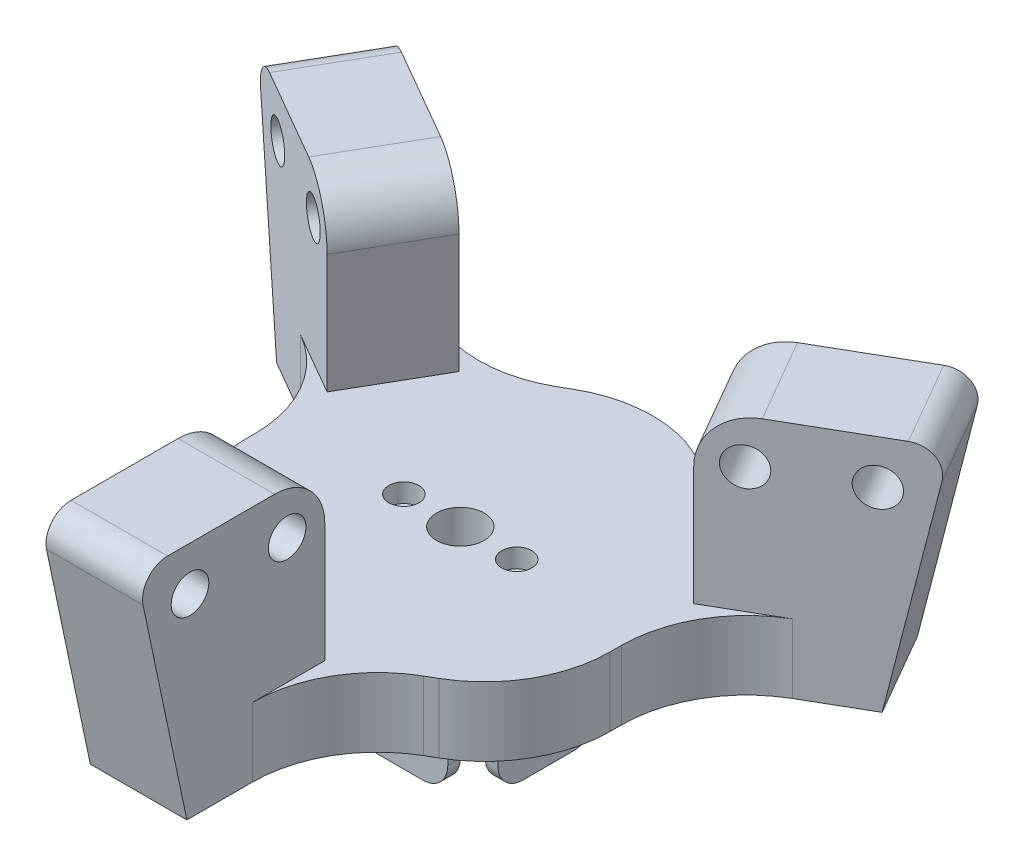
from build123d import *

# Parameters (mm, degrees)
BOSS_EXTRUSION_DEPTH     = 5.5
SCHIZZO2_W               = 7.7
SCHIZZO2_H               = 15
EXTERNAL_EXTRUSION_DEPTH = 13.5
SCHIZZO3_R               = 1.9
CETRAL_HOLE_DEPTH        = 6.5
SKETCH1_R                = 1.5
CUT_EXTRUDE1_DEPTH       = 7.7
CIRPATTERN1_COUNT        = 3
FILLET1_R                = 10
FILLET2_R                = 4
FILLET3_R                = 2
SKETCH2_R                = 0.5
CUT_EXTRUDE2_DEPTH       = 7.7
SKETCH2_5_W              = 1
SKETCH2_5_H              = 8
SKETCH2_5_W_2            = 10
SKETCH2_5_H_2            = 1
BOSS_EXTRUDE1_DEPTH      = 7.5
FILLET4_R                = 2
CHAMFER1_SIZE            = 2
SKETCH2_6_R              = 1.2
SKETCH2_6_R_2            = 1.9
SKETCH2_6_R_3            = 0.5
CUT_EXTRUDE4_DEPTH       = 1.5
CUT_EXTRUDE5_START       = -5.5
SKETCH2_7_R              = 1.2
SKETCH2_7_R_2            = 0.5
CUT_EXTRUDE5_DEPTH       = 1.5
SKETCH4_R                = 2.5
CUT_EXTRUDE6_DEPTH       = 0.7


with BuildPart() as part:
    # Schizzo1 → Boss extrusion (new body)
    with BuildSketch(Plane(origin=(0, 0, 0), x_dir=(1, 0, 0), z_dir=(0, 1, 0))):
        Polygon((-27.611313476, 11.495802195), (-14.620932419, 3.995802195), (-14.620932419, -8.441399268), (-3.85, -14.66), (-3.85, -29.66), (3.85, -29.66), (3.85, -14.66), (14.620932419, -8.441399268), (14.620932419, 3.995802195), (27.611313476, 11.495802195), (23.761313476, 18.164197805), (10.770932419, 10.664197805), (0, 16.882798536), (-10.770932419, 10.664197805), (-23.761313476, 18.164197805), align=None)
    extrude(amount=BOSS_EXTRUSION_DEPTH)

    # Schizzo2 → external extrusion (add)
    with BuildSketch(Plane(origin=(0, 5.5, 0), x_dir=(1, 0, 0), z_dir=(0, 1, 0))):
        Polygon((-23.761313476, 18.164197805), (-27.611313476, 11.495802195), (-14.620932419, 3.995802195), (-10.770932419, 10.664197805), align=None)
        with Locations((0, -22.16)):
            Rectangle(SCHIZZO2_W, SCHIZZO2_H)
        Polygon((10.770932419, 10.664197805), (14.620932419, 3.995802195), (27.611313476, 11.495802195), (23.761313476, 18.164197805), align=None)
    extrude(amount=EXTERNAL_EXTRUSION_DEPTH)

    # Schizzo3 → cetral hole (cut, through all)
    with BuildSketch(Plane(origin=(0, 5.5, 0), x_dir=(1, 0, 0), z_dir=(0, 1, 0))):
        Circle(SCHIZZO3_R)
    extrude(amount=-CETRAL_HOLE_DEPTH, mode=Mode.SUBTRACT)

    # Sketch1 → Cut-Extrude1 (cut)
    with BuildSketch(Plane.ZY.offset(3.85)):
        with Locations((17.66, 15.5)):
            Circle(SKETCH1_R)
        with Locations((25.41, 15.5)):
            Circle(SKETCH1_R)
        Polygon((29.66, 19), (29.66, 0), (25.66, 0), align=None)
    cut_extrude1 = extrude(amount=-CUT_EXTRUDE1_DEPTH, mode=Mode.SUBTRACT)

    # CirPattern1: Cut-Extrude1 ×3 about axis
    cirpattern1_axis = Axis((0, 0, 0), (0, 1, 0))
    for i in range(1, CIRPATTERN1_COUNT):
        add(cut_extrude1.rotate(cirpattern1_axis, i * 360 / CIRPATTERN1_COUNT), mode=Mode.SUBTRACT)

    # Fillet1
    fillet1_edges = [part.edges().sort_by_distance(p)[0] for p in [
        (-3.85, 2.75, 14.66),
        (-14.620932419, 2.75, 8.441399268),
        (-14.620932419, 2.75, -3.995802195),
        (-10.770932419, 2.75, -10.664197805),
        (0, 2.75, -16.882798536),
        (10.770932419, 2.75, -10.664197805),
        (14.620932419, 2.75, -3.995802195),
        (14.620932419, 2.75, 8.441399268),
        (3.85, 2.75, 14.66),
    ]]
    fillet(fillet1_edges, radius=FILLET1_R)

    # Fillet2
    fillet2_edges = [part.edges().sort_by_distance(p)[0] for p in [
        (-12.695932419, 19, -7.33),
        (0, 19, 14.66),
        (12.695932419, 19, -7.33),
    ]]
    fillet(fillet2_edges, radius=FILLET2_R)

    # Fillet3
    fillet3_edges = [part.edges().sort_by_distance(p)[0] for p in [
        (-25.686313476, 19, -14.83),
        (0, 19, 29.66),
        (25.686313476, 19, -14.83),
    ]]
    fillet(fillet3_edges, radius=FILLET3_R)

    # Sketch2 → Cut-Extrude2 (cut)
    with BuildSketch(Plane.XZ):
        with Locations((-4.5, 0)):
            Circle(SKETCH2_R)
        with Locations((4.5, 0)):
            Circle(SKETCH2_R)
    extrude(amount=-CUT_EXTRUDE2_DEPTH, mode=Mode.SUBTRACT)

    # Sketch2_5 → Boss-Extrude1 (add)
    with BuildSketch(Plane.XZ):
        with Locations((6.5, 0)):
            Rectangle(SKETCH2_5_W, SKETCH2_5_H)
        with Locations((0, 5.5)):
            Rectangle(SKETCH2_5_W_2, SKETCH2_5_H_2)
        with Locations((-6.5, 0)):
            Rectangle(SKETCH2_5_W, SKETCH2_5_H)
        with Locations((0, -5.5)):
            Rectangle(SKETCH2_5_W_2, SKETCH2_5_H_2)
    extrude(amount=BOSS_EXTRUDE1_DEPTH)

    # Fillet4
    fillet4_edges = [part.edges().sort_by_distance(p)[0] for p in [
        (6.5, -7.5, 4),
        (6.5, -7.5, -4),
        (-5, -7.5, 5.5),
        (5, -7.5, 5.5),
        (-6.5, -7.5, -4),
        (-6.5, -7.5, 4),
        (5, -7.5, -5.5),
        (-5, -7.5, -5.5),
    ]]
    fillet(fillet4_edges, radius=FILLET4_R)

    # Chamfer1
    chamfer1_edges = [part.edges().sort_by_distance(p)[0] for p in [
        (7, 0, 0),
        (0, 0, 6),
        (-7, 0, 0),
        (0, 0, -6),
    ]]
    chamfer(chamfer1_edges, length=CHAMFER1_SIZE)

    # Sketch2_6 → Cut-Extrude4 (cut)
    with BuildSketch(Plane.XZ):
        Polygon((-6, 4), (-6, -4), (-6, -5), (-5, -5), (5, -5), (6, -5), (6, -4), (6, 4), (6, 5), (5, 5), (-5, 5), (-6, 5), align=None)
        with Locations((-4.5, 0)):
            Circle(SKETCH2_6_R, mode=Mode.SUBTRACT)
        Circle(SKETCH2_6_R_2, mode=Mode.SUBTRACT)
        with Locations((4.5, 0)):
            Circle(SKETCH2_6_R, mode=Mode.SUBTRACT)
        with Locations((-4.5, 0)):
            Circle(SKETCH2_6_R)
        with Locations((-4.5, 0)):
            Circle(SKETCH2_6_R_3, mode=Mode.SUBTRACT)
        with Locations((4.5, 0)):
            Circle(SKETCH2_6_R)
        with Locations((4.5, 0)):
            Circle(SKETCH2_6_R_3, mode=Mode.SUBTRACT)
    extrude(amount=-CUT_EXTRUDE4_DEPTH, mode=Mode.SUBTRACT)

    # Sketch2_7 → Cut-Extrude5 (cut)
    with BuildSketch(Plane.XZ.offset(CUT_EXTRUDE5_START)):
        with Locations((-4.5, 0)):
            Circle(SKETCH2_7_R)
        with Locations((-4.5, 0)):
            Circle(SKETCH2_7_R_2, mode=Mode.SUBTRACT)
        with Locations((4.5, 0)):
            Circle(SKETCH2_7_R)
        with Locations((4.5, 0)):
            Circle(SKETCH2_7_R_2, mode=Mode.SUBTRACT)
    extrude(amount=CUT_EXTRUDE5_DEPTH, mode=Mode.SUBTRACT)

    # Sketch4 → Cut-Extrude6 (cut)
    with BuildSketch(Plane.XZ.offset(-1.5)):
        Circle(SKETCH4_R)
    extrude(amount=-CUT_EXTRUDE6_DEPTH, mode=Mode.SUBTRACT)


solid = part.part
